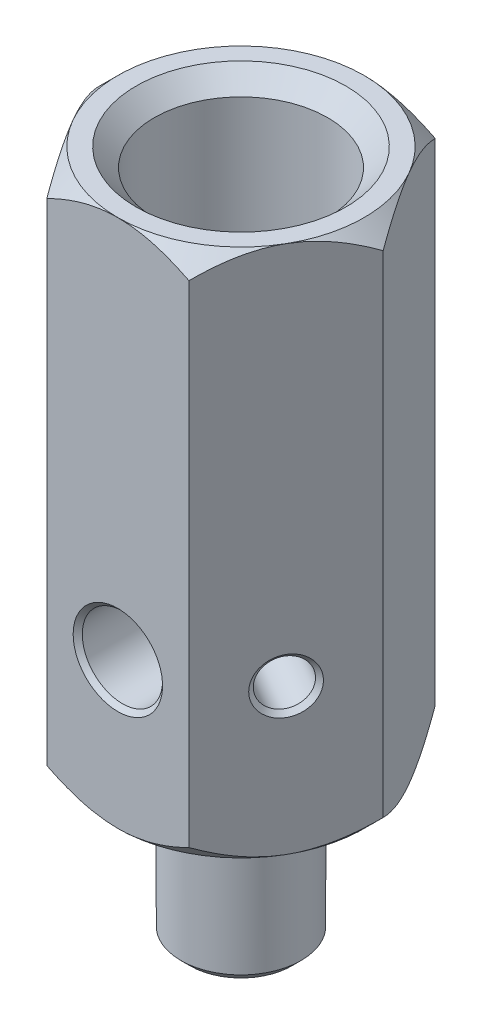
from build123d import *

# Parameters (mm, degrees)
BOSS_EXTRUDE1_DEPTH = 75
SKETCH2_R           = 6.58
CUT_EXTRUDE1_DEPTH  = 15
SKETCH3_OUTSIDE_W   = 50.294
SKETCH3_OUTSIDE_H   = 46.118
SKETCH3_OUTSIDE_R   = 5.5
CUT_EXTRUDE3_DEPTH  = 2
SKETCH4_R           = 3.4
CUT_EXTRUDE4_DEPTH  = 76
SKETCH5_R           = 5.9
CUT_EXTRUDE5_DEPTH  = 36
SKETCH7_R           = 9.5
CUT_EXTRUDE7_DEPTH  = 19
SKETCH8_R           = 4.4
CUT_EXTRUDE8_DEPTH  = 28
SKETCH9_R           = 2.5
CUT_EXTRUDE9_DEPTH  = 34.75000005
CHAMFER2_SIZE       = 0.5
CHAMFER3_SIZE       = 2
CHAMFER4_SIZE       = 1


with BuildPart() as part:
    # Sketch1 → Boss-Extrude1 (new body)
    with BuildSketch(Plane(origin=(0, 0, 0), x_dir=(1, 0, 0), z_dir=(0, 1, 0))):
        Polygon((7.794228634, -13.5), (15.588457268, 0), (7.794228634, 13.5), (-7.794228634, 13.5), (-15.588457268, 0), (-7.794228634, -13.5), align=None)
    extrude(amount=BOSS_EXTRUDE1_DEPTH)

    # Sketch2 → Cut-Extrude1 (cut)
    with BuildSketch(Plane.XZ):
        Polygon((15.588457268, 0), (7.794228634, 13.5), (-7.794228634, 13.5), (-15.588457268, 0), (-7.794228634, -13.5), (7.794228634, -13.5), align=None)
        Circle(SKETCH2_R, mode=Mode.SUBTRACT)
    extrude(amount=-CUT_EXTRUDE1_DEPTH, mode=Mode.SUBTRACT)

    # Sketch3 outside → Cut-Extrude3 (cut)
    with BuildSketch(Plane.XZ.offset(-15)):
        Rectangle(SKETCH3_OUTSIDE_W, SKETCH3_OUTSIDE_H)
        Circle(SKETCH3_OUTSIDE_R, mode=Mode.SUBTRACT)
    extrude(amount=-CUT_EXTRUDE3_DEPTH, mode=Mode.SUBTRACT)

    # Sketch4 → Cut-Extrude4 (cut, through all)
    with BuildSketch(Plane.XZ):
        Circle(SKETCH4_R)
    extrude(amount=-CUT_EXTRUDE4_DEPTH, mode=Mode.SUBTRACT)

    # Sketch5 → Cut-Extrude5 (cut)
    with BuildSketch(Plane(origin=(0, 75, 0), x_dir=(1, 0, 0), z_dir=(0, 1, 0))):
        Circle(SKETCH5_R)
    extrude(amount=-CUT_EXTRUDE5_DEPTH, mode=Mode.SUBTRACT)

    # Sketch7 → Cut-Extrude7 (cut)
    with BuildSketch(Plane(origin=(0, 75, 0), x_dir=(1, 0, 0), z_dir=(0, 1, 0))):
        Circle(SKETCH7_R)
    extrude(amount=-CUT_EXTRUDE7_DEPTH, mode=Mode.SUBTRACT)

    # Sketch8 → Cut-Extrude8 (cut, through all)
    with BuildSketch(Plane.XY.offset(13.5)):
        with Locations((0, 33)):
            Circle(SKETCH8_R)
    extrude(amount=-CUT_EXTRUDE8_DEPTH, mode=Mode.SUBTRACT)

    # Sketch9 → Cut-Extrude9 (cut, through all)
    with BuildSketch(Plane(origin=(-11.691342951, 0, -6.75), x_dir=(-0.5, 0, 0.866025404), z_dir=(-0.866025404, 0, -0.5))):
        with Locations((0, 33)):
            Circle(SKETCH9_R)
    extrude(amount=-CUT_EXTRUDE9_DEPTH, mode=Mode.SUBTRACT)

    # Sketch10 → Cut-Revolve1 (revolve, cut)
    with BuildSketch(Plane(origin=(0, 0, 0), x_dir=(0, 0, -1), z_dir=(1, 0, 0))):
        Polygon((8.51850403, 79.98149597), (18.48149597, 70.01850403), (18.48149597, 79.98149597), align=None)
        Polygon((16.279129623, 19.779129623), (10.720870377, 14.220870377), (16.279129623, 14.220870377), align=None)
    revolve(axis=Axis((0, 77.98149597, 0), (0, -1, 0)), mode=Mode.SUBTRACT)

    # Chamfer2
    chamfer2_edges = [part.edges().sort_by_distance(p)[0] for p in [
        (-10.441342951, 33, -8.915063509),
        (-3.4, 0, 0),
        (-3.4, 39, 0),
        (-5.9, 56, 0),
        (-4.4, 33, -13.5),
        (-4.4, 33, 13.5),
        (12.941342951, 33, 4.584936491),
    ]]
    chamfer(chamfer2_edges, length=CHAMFER2_SIZE)

    # Chamfer3
    chamfer3_edges = [part.edges().sort_by_distance(p)[0] for p in [
        (-9.5, 75, 0),
    ]]
    chamfer(chamfer3_edges, length=CHAMFER3_SIZE)

    # Chamfer4
    chamfer4_edges = [part.edges().sort_by_distance(p)[0] for p in [
        (-6.58, 0, 0),
        (-6.58, 15, 0),
    ]]
    chamfer(chamfer4_edges, length=CHAMFER4_SIZE)


solid = part.part
